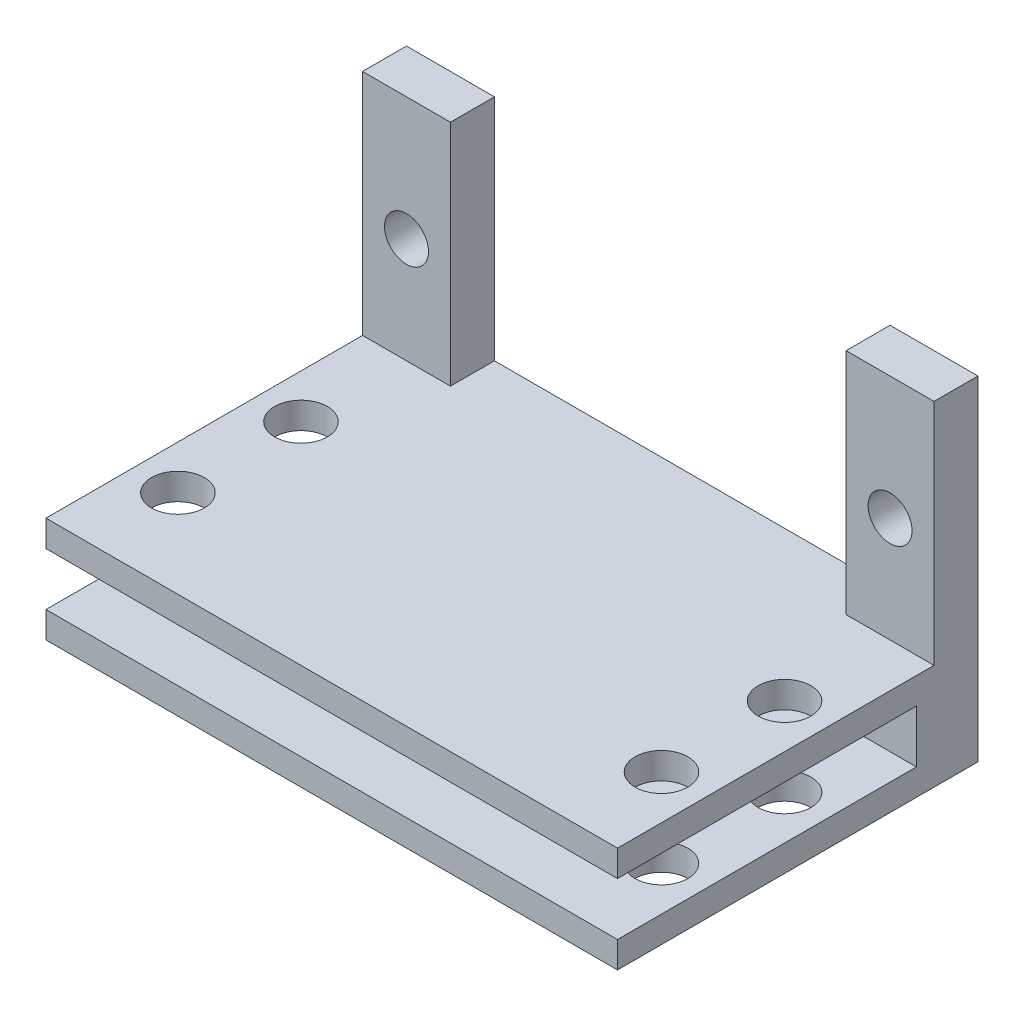
from build123d import *

# Parameters (mm, degrees)
SKETCH1_W               = 5
SKETCH1_H               = 13
SKETCH1_R               = 1.25
BOSS_EXTRUDE1_DEPTH     = 2.5
BOSS_EXTRUDE1_2_DEPTH   = 2.5
SKETCH1_5_W             = 32.5
SKETCH1_5_H             = 1.5
BOSS_EXTRUDE2_DEPTH     = 20.5
SKETCH1_6_W             = 32.5
SKETCH1_6_H             = 3
BOSS_EXTRUDE3_DEPTH     = 3.5
CUT_EXTRUDE2_DEPTH      = 30.211513141
CUT_EXTRUDE2_DEPTH_BACK = 30.211513141
SKETCH2_R               = 1.5


with BuildPart() as part:
    # Sketch1 → Boss-Extrude1 (new body)
    with BuildSketch(Plane.XY):
        with Locations((-13.75, 6.5)):
            Rectangle(SKETCH1_W, SKETCH1_H)
        with Locations((-13.75, 6)):
            Circle(SKETCH1_R, mode=Mode.SUBTRACT)
    extrude(amount=BOSS_EXTRUDE1_DEPTH)



with BuildPart() as body_2:
    # Sketch1 → Boss-Extrude1 2 (new body)
    with BuildSketch(Plane.XY):
        with Locations((13.75, 6.5)):
            Rectangle(SKETCH1_W, SKETCH1_H)
        with Locations((13.75, 6)):
            Circle(SKETCH1_R, mode=Mode.SUBTRACT)
    extrude(amount=BOSS_EXTRUDE1_2_DEPTH)


with BuildPart() as part_1:
    add(part.part)

    add(body_2.part)  # Boss-Extrude2 merges body 2
    # Sketch1_5 → Boss-Extrude2 (add)
    with BuildSketch(Plane.XY):
        with Locations((0, -0.75)):
            Rectangle(SKETCH1_5_W, SKETCH1_5_H)
        with Locations((0, -5.25)):
            Rectangle(SKETCH1_5_W, SKETCH1_5_H)
    extrude(amount=BOSS_EXTRUDE2_DEPTH)

    # Sketch1_6 → Boss-Extrude3 (add)
    with BuildSketch(Plane.XY):
        with Locations((0, -3)):
            Rectangle(SKETCH1_6_W, SKETCH1_6_H)
    extrude(amount=BOSS_EXTRUDE3_DEPTH)

    # Sketch2 → Cut-Extrude2 (cut, two sides: drawn at the far end of the back side and taken through both)
    with BuildSketch(Plane(origin=(0, 0, 0), x_dir=(1, 0, 0), z_dir=(0, 1, 0)).offset(-CUT_EXTRUDE2_DEPTH_BACK)):
        with Locations((13.75, -8.5)):
            Circle(SKETCH2_R)
        with Locations((13.75, -15.5)):
            Circle(SKETCH2_R)
        with Locations((-13.75, -15.5)):
            Circle(SKETCH2_R)
        with Locations((-13.75, -8.5)):
            Circle(SKETCH2_R)
    extrude(amount=CUT_EXTRUDE2_DEPTH + CUT_EXTRUDE2_DEPTH_BACK, mode=Mode.SUBTRACT)


solid = part_1.part
